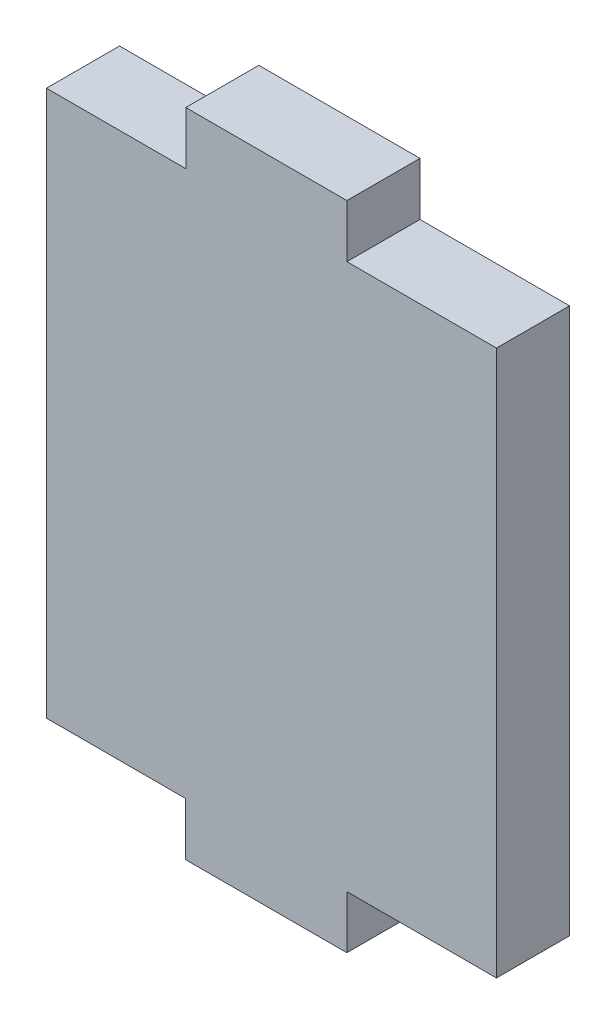
from build123d import *

# Parameters (mm, degrees)
SKETCH1_W           = 20
SKETCH1_H           = 23.7
BOSS_EXTRUDE1_DEPTH = 3.175
SKETCH2_W           = 7
SKETCH2_H           = 2.3
BOSS_EXTRUDE2_DEPTH = 3.175
SKETCH3_W           = 0.45
SKETCH3_H           = 23.7
CUT_EXTRUDE1_DEPTH  = 10


with BuildPart() as part:
    # Sketch1 → Boss-Extrude1 (new body)
    with BuildSketch(Plane.XY):
        with Locations((10, 11.85)):
            Rectangle(SKETCH1_W, SKETCH1_H)
    extrude(amount=BOSS_EXTRUDE1_DEPTH)

    # Sketch2 → Boss-Extrude2 (add)
    with BuildSketch(Plane.XY.offset(3.175)):
        with Locations((10.002051165, 24.85)):
            Rectangle(SKETCH2_W, SKETCH2_H)
        with Locations((10, -1.15)):
            Rectangle(SKETCH2_W, SKETCH2_H)
    extrude(amount=-BOSS_EXTRUDE2_DEPTH)

    # Sketch3 → Cut-Extrude1 (cut)
    with BuildSketch(Plane.XY.offset(3.175)):
        with Locations((0.225, 11.85)):
            Rectangle(SKETCH3_W, SKETCH3_H)
    extrude(amount=-CUT_EXTRUDE1_DEPTH, mode=Mode.SUBTRACT)


solid = part.part
